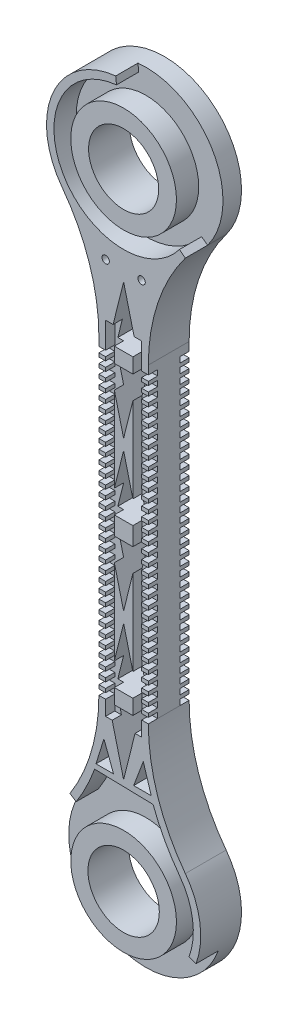
from build123d import *

# Parameters (mm, degrees)
MAIN_BONE_DEPTH      = 12.7
SKETCH4_R            = 36.195
KNEE_ENCLOSER_DEPTH  = 15.24
SKETCH5_R            = 36.195
THIGH_ENCLOSER_DEPTH = 15.24
BOSS_EXTRUDE4_DEPTH  = 15.24
SKETCH7_R            = 24.455055929
SKETCH7_R_2          = 24.005043079
CUT_EXTRUDE1_DEPTH   = 28.94
SKETCH8_W            = 4.572
SKETCH8_H            = 3.81
CUT_EXTRUDE2_DEPTH   = 6.35
SKETCH9_W            = 6.0149078
SKETCH9_H            = 235.046071976
CUT_EXTRUDE3_DEPTH   = 6.35
SKETCH12_R           = 2.54
CUT_EXTRUDE4_DEPTH   = 28.94


with BuildPart() as part:
    # Sketch3 → main_Bone (new body)
    with BuildSketch(Plane.XY):
        with BuildLine():
            Line((-16.935344641, 267.852098609), (-16.935344641, 54.968618103))
            ThreePointArc((-16.935344641, 54.968618103), (-23.43835483, 14.850349863), (-42.281414665, -21.159422201))
            ThreePointArc((-42.281414665, -21.159422201), (0, -105.647458268), (42.281414665, -21.159422201))
            ThreePointArc((42.281414665, -21.159422201), (23.43835483, 14.850349863), (16.935344641, 54.968618103))
            Line((16.935344641, 54.968618103), (16.935344641, 267.852098609))
            ThreePointArc((16.935344641, 267.852098609), (23.43835483, 307.970366848), (42.281414665, 343.980138912))
            ThreePointArc((42.281414665, 343.980138912), (0, 428.468174979), (-42.281414665, 343.980138912))
            ThreePointArc((-42.281414665, 343.980138912), (-23.43835483, 307.970366848), (-16.935344641, 267.852098609))
        make_face()
    extrude(amount=MAIN_BONE_DEPTH)

    # Sketch4 → knee _encloser (add)
    with BuildSketch(Plane.XY.offset(12.7)):
        with Locations((0, -52.823729134)):
            Circle(SKETCH4_R)
        with BuildLine():
            Line((44.83537496, -69.23265426), (49.605921981, -70.978586996))
            ThreePointArc((49.605921981, -70.978586996), (52.261916863, -45.140083814), (42.281414665, -21.159422201))
            ThreePointArc((42.281414665, -21.159422201), (32.971927644, -6.806134736), (25.676028026, 8.668142578))
            Line((25.676028026, 8.668142578), (20.188372093, 8.797055585))
            ThreePointArc((20.188372093, 8.797055585), (28.021327951, -8.34857652), (38.215257466, -24.204543813))
            ThreePointArc((38.215257466, -24.204543813), (47.235945732, -45.879011543), (44.83537496, -69.23265426))
        make_face()
        with BuildLine():
            Line((-32.489858198, -15.918827552), (-36.776223061, -13.192387335))
            ThreePointArc((-36.776223061, -13.192387335), (-30.40874634, -1.958629138), (-25.214910979, 9.863644639))
            Line((-25.214910979, 9.863644639), (-19.84157021, 9.737417061))
            ThreePointArc((-19.84157021, 9.737417061), (-25.469119179, -3.43412006), (-32.489858198, -15.918827552))
        make_face()
    extrude(amount=KNEE_ENCLOSER_DEPTH)

    # Sketch5 → thigh_encloser (add)
    with BuildSketch(Plane.XY.offset(12.7)):
        with Locations((0, 375.644445845)):
            Circle(SKETCH5_R)
        with BuildLine():
            Line((-38.215257466, 347.025260524), (-42.281414665, 343.980138912))
            ThreePointArc((-42.281414665, 343.980138912), (-48.388406454, 396.831906297), (-5.40885795, 428.19052672))
            Line((-5.40885795, 428.19052672), (-4.888694023, 423.137227848))
            ThreePointArc((-4.888694023, 423.137227848), (-43.734946564, 394.794331502), (-38.215257466, 347.025260524))
        make_face()
    extrude(amount=THIGH_ENCLOSER_DEPTH)

    # Sketch6 → Boss-Extrude4 (add)
    with BuildSketch(Plane.XY.offset(12.7)):
        with BuildLine():
            Line((-25.214910979, 9.863644639), (25.676028026, 8.668142578))
            ThreePointArc((25.676028026, 8.668142578), (19.139645175, 31.409471366), (16.935344641, 54.968618103))
            Line((16.935344641, 54.968618103), (16.935344641, 267.852098609))
            ThreePointArc((16.935344641, 267.852098609), (23.43835483, 307.970366848), (42.281414665, 343.980138912))
            Line((42.281414665, 343.980138912), (38.215257466, 347.025260524))
            ThreePointArc((38.215257466, 347.025260524), (0, 327.900716711), (-38.215257466, 347.025260524))
            Line((-38.215257466, 347.025260524), (-42.281414665, 343.980138912))
            ThreePointArc((-42.281414665, 343.980138912), (-23.43835483, 307.970366848), (-16.935344641, 267.852098609))
            Line((-16.935344641, 267.852098609), (-16.935344641, 54.968618103))
            ThreePointArc((-16.935344641, 54.968618103), (-19.022384795, 32.03932543), (-25.214910979, 9.863644639))
        make_face()
    extrude(amount=BOSS_EXTRUDE4_DEPTH)

    # Sketch7 → Cut-Extrude1 (cut, through all)
    with BuildSketch(Plane.XY.offset(27.94)):
        with Locations((0, -52.823729134)):
            Circle(SKETCH7_R)
        with Locations((0, 375.644445845)):
            Circle(SKETCH7_R_2)
        Polygon((0, 308.721666921), (-10.296622988, 267.422865696), (10.296622988, 267.422865696), align=None)
        Polygon((-10.296622988, 257.197074126), (10.296622988, 257.197074126), (0, 215.898272902), align=None)
        Polygon((0, 208.600163908), (-10.296622988, 167.301362684), (10.296622988, 167.301362684), align=None)
        Polygon((0, 113.479918194), (10.296622988, 154.778719418), (-10.296622988, 154.778719418), align=None)
        Polygon((0, 106.1818092), (10.296622988, 64.883007976), (-10.296622988, 64.883007976), align=None)
        Polygon((0, 13.358415181), (10.296622988, 54.657216406), (-10.296622988, 54.657216406), align=None)
        Polygon((-13.483155622, 30.916817133), (-18.909403622, 13.358415181), (-6.873753563, 13.358415181), align=None)
        Polygon((18.909403622, 13.358415181), (6.873753563, 13.358415181), (13.483155622, 30.916817133), align=None)
    extrude(amount=-CUT_EXTRUDE1_DEPTH, mode=Mode.SUBTRACT)

    # Sketch8 → Cut-Extrude2 (cut)
    with BuildSketch(Plane.XY.offset(27.94)):
        with Locations((14.649344641, 56.873618103)):
            Rectangle(SKETCH8_W, SKETCH8_H)
        with Locations((14.649344641, 63.223618103)):
            Rectangle(SKETCH8_W, SKETCH8_H)
        with Locations((14.649344641, 69.573618103)):
            Rectangle(SKETCH8_W, SKETCH8_H)
        with Locations((14.649344641, 75.923618103)):
            Rectangle(SKETCH8_W, SKETCH8_H)
        with Locations((14.649344641, 82.273618103)):
            Rectangle(SKETCH8_W, SKETCH8_H)
        with Locations((14.649344641, 88.623618103)):
            Rectangle(SKETCH8_W, SKETCH8_H)
        with Locations((14.649344641, 94.973618103)):
            Rectangle(SKETCH8_W, SKETCH8_H)
        with Locations((14.649344641, 101.323618103)):
            Rectangle(SKETCH8_W, SKETCH8_H)
        with Locations((14.649344641, 107.673618103)):
            Rectangle(SKETCH8_W, SKETCH8_H)
        with Locations((14.649344641, 114.023618103)):
            Rectangle(SKETCH8_W, SKETCH8_H)
        with Locations((14.649344641, 120.373618103)):
            Rectangle(SKETCH8_W, SKETCH8_H)
        with Locations((14.649344641, 126.723618103)):
            Rectangle(SKETCH8_W, SKETCH8_H)
        with Locations((14.649344641, 133.073618103)):
            Rectangle(SKETCH8_W, SKETCH8_H)
        with Locations((14.649344641, 139.423618103)):
            Rectangle(SKETCH8_W, SKETCH8_H)
        with Locations((14.649344641, 145.773618103)):
            Rectangle(SKETCH8_W, SKETCH8_H)
        with Locations((14.649344641, 152.123618103)):
            Rectangle(SKETCH8_W, SKETCH8_H)
        with Locations((14.649344641, 158.473618103)):
            Rectangle(SKETCH8_W, SKETCH8_H)
        with Locations((14.649344641, 164.823618103)):
            Rectangle(SKETCH8_W, SKETCH8_H)
        with Locations((14.649344641, 171.173618103)):
            Rectangle(SKETCH8_W, SKETCH8_H)
        with Locations((14.649344641, 177.523618103)):
            Rectangle(SKETCH8_W, SKETCH8_H)
        with Locations((14.649344641, 183.873618103)):
            Rectangle(SKETCH8_W, SKETCH8_H)
        with Locations((14.649344641, 190.223618103)):
            Rectangle(SKETCH8_W, SKETCH8_H)
        with Locations((14.649344641, 196.573618103)):
            Rectangle(SKETCH8_W, SKETCH8_H)
        with Locations((14.649344641, 202.923618103)):
            Rectangle(SKETCH8_W, SKETCH8_H)
        with Locations((14.649344641, 209.273618103)):
            Rectangle(SKETCH8_W, SKETCH8_H)
        with Locations((14.649344641, 215.623618103)):
            Rectangle(SKETCH8_W, SKETCH8_H)
        with Locations((14.649344641, 221.973618103)):
            Rectangle(SKETCH8_W, SKETCH8_H)
        with Locations((14.649344641, 228.323618103)):
            Rectangle(SKETCH8_W, SKETCH8_H)
        with Locations((14.649344641, 234.673618103)):
            Rectangle(SKETCH8_W, SKETCH8_H)
        with Locations((14.649344641, 241.023618103)):
            Rectangle(SKETCH8_W, SKETCH8_H)
        with Locations((14.649344641, 247.373618103)):
            Rectangle(SKETCH8_W, SKETCH8_H)
        with Locations((14.649344641, 253.723618103)):
            Rectangle(SKETCH8_W, SKETCH8_H)
        with Locations((14.649344641, 260.073618103)):
            Rectangle(SKETCH8_W, SKETCH8_H)
        with Locations((-14.649344641, 260.073618103)):
            Rectangle(SKETCH8_W, SKETCH8_H)
        with Locations((-14.649344641, 253.723618103)):
            Rectangle(SKETCH8_W, SKETCH8_H)
        with Locations((-14.649344641, 247.373618103)):
            Rectangle(SKETCH8_W, SKETCH8_H)
        with Locations((-14.649344641, 241.023618103)):
            Rectangle(SKETCH8_W, SKETCH8_H)
        with Locations((-14.649344641, 234.673618103)):
            Rectangle(SKETCH8_W, SKETCH8_H)
        with Locations((-14.649344641, 228.323618103)):
            Rectangle(SKETCH8_W, SKETCH8_H)
        with Locations((-14.649344641, 221.973618103)):
            Rectangle(SKETCH8_W, SKETCH8_H)
        with Locations((-14.649344641, 215.623618103)):
            Rectangle(SKETCH8_W, SKETCH8_H)
        with Locations((-14.649344641, 209.273618103)):
            Rectangle(SKETCH8_W, SKETCH8_H)
        with Locations((-14.649344641, 202.923618103)):
            Rectangle(SKETCH8_W, SKETCH8_H)
        with Locations((-14.649344641, 196.573618103)):
            Rectangle(SKETCH8_W, SKETCH8_H)
        with Locations((-14.649344641, 190.223618103)):
            Rectangle(SKETCH8_W, SKETCH8_H)
        with Locations((-14.649344641, 183.873618103)):
            Rectangle(SKETCH8_W, SKETCH8_H)
        with Locations((-14.649344641, 177.523618103)):
            Rectangle(SKETCH8_W, SKETCH8_H)
        with Locations((-14.649344641, 171.173618103)):
            Rectangle(SKETCH8_W, SKETCH8_H)
        with Locations((-14.649344641, 164.823618103)):
            Rectangle(SKETCH8_W, SKETCH8_H)
        with Locations((-14.649344641, 158.473618103)):
            Rectangle(SKETCH8_W, SKETCH8_H)
        with Locations((-14.649344641, 152.123618103)):
            Rectangle(SKETCH8_W, SKETCH8_H)
        with Locations((-14.649344641, 145.773618103)):
            Rectangle(SKETCH8_W, SKETCH8_H)
        with Locations((-14.649344641, 139.423618103)):
            Rectangle(SKETCH8_W, SKETCH8_H)
        with Locations((-14.649344641, 133.073618103)):
            Rectangle(SKETCH8_W, SKETCH8_H)
        with Locations((-14.649344641, 126.723618103)):
            Rectangle(SKETCH8_W, SKETCH8_H)
        with Locations((-14.649344641, 120.373618103)):
            Rectangle(SKETCH8_W, SKETCH8_H)
        with Locations((-14.649344641, 114.023618103)):
            Rectangle(SKETCH8_W, SKETCH8_H)
        with Locations((-14.649344641, 107.673618103)):
            Rectangle(SKETCH8_W, SKETCH8_H)
        with Locations((-14.649344641, 101.323618103)):
            Rectangle(SKETCH8_W, SKETCH8_H)
        with Locations((-14.649344641, 94.973618103)):
            Rectangle(SKETCH8_W, SKETCH8_H)
        with Locations((-14.649344641, 88.623618103)):
            Rectangle(SKETCH8_W, SKETCH8_H)
        with Locations((-14.649344641, 82.273618103)):
            Rectangle(SKETCH8_W, SKETCH8_H)
        with Locations((-14.649344641, 75.923618103)):
            Rectangle(SKETCH8_W, SKETCH8_H)
        with Locations((-14.649344641, 69.573618103)):
            Rectangle(SKETCH8_W, SKETCH8_H)
        with Locations((-14.649344641, 63.223618103)):
            Rectangle(SKETCH8_W, SKETCH8_H)
        with Locations((-14.649344641, 56.873618103)):
            Rectangle(SKETCH8_W, SKETCH8_H)
    cut_extrude2 = extrude(amount=-CUT_EXTRUDE2_DEPTH, mode=Mode.SUBTRACT)

    # Sketch9 → Cut-Extrude3 (cut)
    with BuildSketch(Plane.XY.offset(27.94)):
        with Locations((9.355890741, 162.29941281)):
            Rectangle(SKETCH9_W, SKETCH9_H)
        with Locations((-9.355890741, 162.29941281)):
            Rectangle(SKETCH9_W, SKETCH9_H)
    cut_extrude3 = extrude(amount=-CUT_EXTRUDE3_DEPTH, mode=Mode.SUBTRACT)

    # Mirror2: Cut-Extrude2, Cut-Extrude3 across plane
    add(cut_extrude2.mirror(Plane.XY.offset(13.97)), mode=Mode.SUBTRACT)
    add(cut_extrude3.mirror(Plane.XY.offset(13.97)), mode=Mode.SUBTRACT)

    # Sketch12 → Cut-Extrude4 (cut, through all)
    with BuildSketch(Plane.XY.offset(27.94)):
        with Locations((-12.295784926, 315.834568213)):
            Circle(SKETCH12_R)
        with Locations((12.295784926, 315.834568213)):
            Circle(SKETCH12_R)
    extrude(amount=-CUT_EXTRUDE4_DEPTH, mode=Mode.SUBTRACT)


solid = part.part
